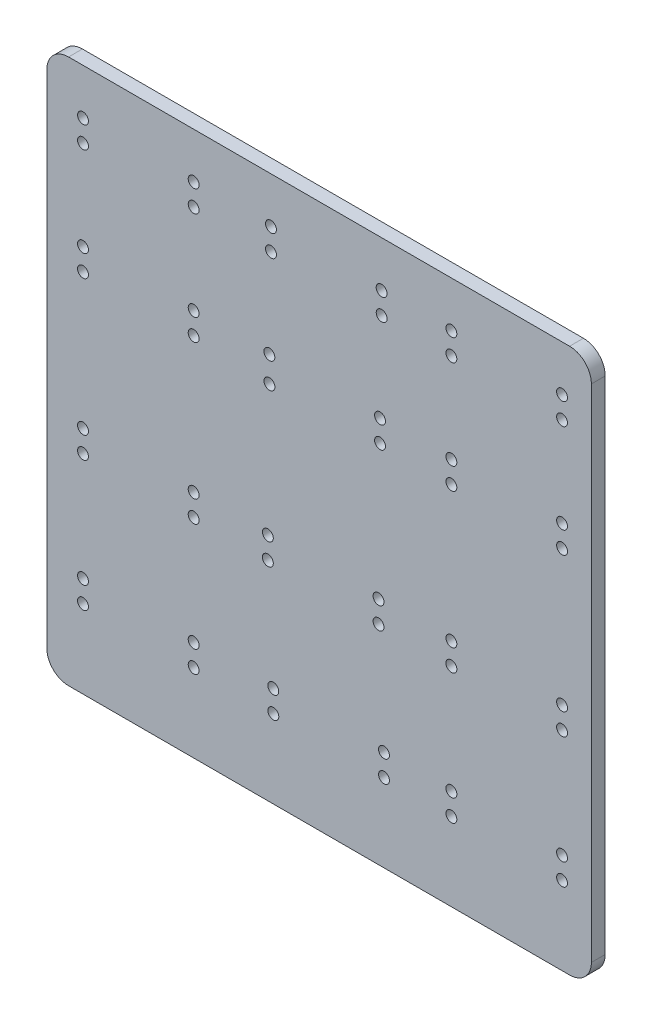
from build123d import *

# Parameters (mm, degrees)
SKETCH1_W                   = 250
SKETCH1_H                   = 250
BOSS_EXTRUDE1_DEPTH         = 6.35
FILLET1_R                   = 10
TAP_DRILL_FOR_M6X1_0_TAP1_D = 5
TAP_DRILL_FOR_M6X1_0_TAP2_D = 5
TAP_DRILL_FOR_M6X1_0_TAP3_D = 5


with BuildPart() as part:
    # Sketch1 → Boss-Extrude1 (new body)
    with BuildSketch(Plane(origin=(-15.018309821, 0, 0), x_dir=(1, 0, 0), z_dir=(0, 0, 1))):
        with Locations((75.170478225, 83.366123253)):
            Rectangle(SKETCH1_W, SKETCH1_H)
    extrude(amount=BOSS_EXTRUDE1_DEPTH)

    # Fillet1
    fillet1_edges = [part.edges().sort_by_distance(p)[0] for p in [
        (-64.847831597, 208.366123253, 3.175),
        (185.152168403, 208.366123253, 3.175),
        (185.152168403, -41.633876747, 3.175),
        (-64.847831597, -41.633876747, 3.175),
    ]]
    fillet(fillet1_edges, radius=FILLET1_R)

    # Tap Drill for M6x1.0 Tap1 (through all)
    with Locations(Plane.XY.offset(6.35)):
        with Locations((37.327836752, 136.24557957), (88.127836752, 136.24557957), (37.3593105, 124.457685542), (88.127838497, 126.24557957)):
            Hole(TAP_DRILL_FOR_M6X1_0_TAP1_D / 2)

    # Tap Drill for M6x1.0 Tap2 (through all)
    with Locations(Plane.XY.offset(6.35)):
        with Locations((120.892593903, 187.375248984), (171.692593903, 187.375248984), (171.692593906, 177.375248984), (120.892593906, 177.375248984), (-48.228620318, 187.375248984), (2.571379682, 187.375248984), (2.571379686, 177.375248984), (-48.228620318, 177.375248984), (-48.228620318, 64.020452142), (-48.228620318, 54.020452142), (2.571379682, 64.020452142), (2.571379682, 54.020452142), (2.571379682, 4.309579467), (2.571379682, -5.690420533), (-48.228620318, 4.309579467), (-48.228620318, -5.690420533), (120.892593903, 64.020452142), (171.692593903, 64.020452142), (171.692593903, 54.020452142), (120.892593903, 54.020452142), (120.892593903, 4.309579467), (171.692593903, 4.309579467), (171.692593903, -5.690420533), (120.892593903, -5.690420533), (-48.228620318, 136.245579568), (-48.228620318, 126.245579568), (2.571379686, 136.245579568), (2.571379686, 126.245579568), (120.892593906, 136.245579568), (120.892593906, 126.245579568), (171.692593906, 136.245579568), (171.692593906, 126.245579568)):
            Hole(TAP_DRILL_FOR_M6X1_0_TAP2_D / 2)

    # Tap Drill for M6x1.0 Tap3 (through all)
    with Locations(Plane.XY.offset(6.35)):
        with Locations((38.064970254, 187.375245165), (88.864970254, 187.37524898), (88.875056728, 177.375254067), (38.075056728, 177.375250252), (36.642065603, 64.020452168), (87.442065603, 64.02045214), (87.436525124, 54.020453675), (36.636525124, 54.020453703), (39.131440217, 4.309560284), (89.931440217, 4.30957947), (89.954059606, -5.690394948), (39.154059606, -5.690414135)):
            Hole(TAP_DRILL_FOR_M6X1_0_TAP3_D / 2)


solid = part.part
